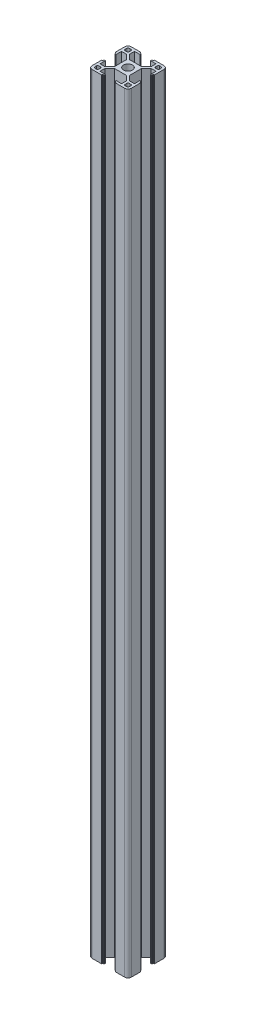
from build123d import *

# Parameters (mm, degrees)
SKETCH_3_R          = 3.4
EXTRUDE_1_DEPTH     = 589
SKETCH_4_R          = 3
CUT_EXTRUDE_1_DEPTH = 87


with BuildPart() as part:
    # 草图3 → 凸台-拉伸1 (new body)
    with BuildSketch(Plane(origin=(0, 0, 0), x_dir=(1, 0, 0), z_dir=(0, 1, 0))):
        with BuildLine():
            Line((-15, -12.5), (-15, -5.4))
            ThreePointArc((-15, -5.4), (-14.941421356, -5.258578644), (-14.8, -5.2))
            Line((-14.8, -5.2), (-14.4, -5.2))
            ThreePointArc((-14.4, -5.2), (-14.258578644, -5.141421356), (-14.2, -5))
            Line((-14.2, -5), (-14.2, -4.3))
            ThreePointArc((-14.2, -4.3), (-14.141421356, -4.158578644), (-14, -4.1))
            Line((-14, -4.1), (-13.2, -4.1))
            Line((-13.2, -4.1), (-13.2, -8.25))
            Line((-13.2, -8.25), (-9.522792206, -8.25))
            Line((-9.522792206, -8.25), (-5.8, -4.527207794))
            Line((-5.8, -4.527207794), (-5.8, 4.527207794))
            Line((-5.8, 4.527207794), (-9.522792206, 8.25))
            Line((-9.522792206, 8.25), (-13.2, 8.25))
            Line((-13.2, 8.25), (-13.2, 4.1))
            Line((-13.2, 4.1), (-14, 4.1))
            ThreePointArc((-14, 4.1), (-14.141421356, 4.158578644), (-14.2, 4.3))
            Line((-14.2, 4.3), (-14.2, 5))
            ThreePointArc((-14.2, 5), (-14.258578644, 5.141421356), (-14.4, 5.2))
            Line((-14.4, 5.2), (-14.8, 5.2))
            ThreePointArc((-14.8, 5.2), (-14.941421356, 5.258578644), (-15, 5.4))
            Line((-15, 5.4), (-15, 12.5))
            ThreePointArc((-15, 12.5), (-14.267766953, 14.267766953), (-12.5, 15))
            Line((-12.5, 15), (-5.4, 15))
            ThreePointArc((-5.4, 15), (-5.258578644, 14.941421356), (-5.2, 14.8))
            Line((-5.2, 14.8), (-5.2, 14.4))
            ThreePointArc((-5.2, 14.4), (-5.141421356, 14.258578644), (-5, 14.2))
            Line((-5, 14.2), (-4.3, 14.2))
            ThreePointArc((-4.3, 14.2), (-4.158578644, 14.141421356), (-4.1, 14))
            Line((-4.1, 14), (-4.1, 13.2))
            Line((-4.1, 13.2), (-8.25, 13.2))
            Line((-8.25, 13.2), (-8.25, 9.522792206))
            Line((-8.25, 9.522792206), (-4.527207794, 5.8))
            Line((-4.527207794, 5.8), (4.527207794, 5.8))
            Line((4.527207794, 5.8), (8.25, 9.522792206))
            Line((8.25, 9.522792206), (8.25, 13.2))
            Line((8.25, 13.2), (4.1, 13.2))
            Line((4.1, 13.2), (4.1, 14))
            ThreePointArc((4.1, 14), (4.158578644, 14.141421356), (4.3, 14.2))
            Line((4.3, 14.2), (5, 14.2))
            ThreePointArc((5, 14.2), (5.141421356, 14.258578644), (5.2, 14.4))
            Line((5.2, 14.4), (5.2, 14.8))
            ThreePointArc((5.2, 14.8), (5.258578644, 14.941421356), (5.4, 15))
            Line((5.4, 15), (12.5, 15))
            ThreePointArc((12.5, 15), (14.267766953, 14.267766953), (15, 12.5))
            Line((15, 12.5), (15, 5.4))
            ThreePointArc((15, 5.4), (14.941421356, 5.258578644), (14.8, 5.2))
            Line((14.8, 5.2), (14.4, 5.2))
            ThreePointArc((14.4, 5.2), (14.258578644, 5.141421356), (14.2, 5))
            Line((14.2, 5), (14.2, 4.3))
            ThreePointArc((14.2, 4.3), (14.141421356, 4.158578644), (14, 4.1))
            Line((14, 4.1), (13.2, 4.1))
            Line((13.2, 4.1), (13.2, 8.25))
            Line((13.2, 8.25), (9.522792206, 8.25))
            Line((9.522792206, 8.25), (5.8, 4.527207794))
            Line((5.8, 4.527207794), (5.8, -4.527207794))
            Line((5.8, -4.527207794), (9.522792206, -8.25))
            Line((9.522792206, -8.25), (13.2, -8.25))
            Line((13.2, -8.25), (13.2, -4.1))
            Line((13.2, -4.1), (14, -4.1))
            ThreePointArc((14, -4.1), (14.141421356, -4.158578644), (14.2, -4.3))
            Line((14.2, -4.3), (14.2, -5))
            ThreePointArc((14.2, -5), (14.258578644, -5.141421356), (14.4, -5.2))
            Line((14.4, -5.2), (14.8, -5.2))
            ThreePointArc((14.8, -5.2), (14.941421356, -5.258578644), (15, -5.4))
            Line((15, -5.4), (15, -12.5))
            ThreePointArc((15, -12.5), (14.267766953, -14.267766953), (12.5, -15))
            Line((12.5, -15), (5.4, -15))
            ThreePointArc((5.4, -15), (5.258578644, -14.941421356), (5.2, -14.8))
            Line((5.2, -14.8), (5.2, -14.4))
            ThreePointArc((5.2, -14.4), (5.141421356, -14.258578644), (5, -14.2))
            Line((5, -14.2), (4.3, -14.2))
            ThreePointArc((4.3, -14.2), (4.158578644, -14.141421356), (4.1, -14))
            Line((4.1, -14), (4.1, -13.2))
            Line((4.1, -13.2), (8.25, -13.2))
            Line((8.25, -13.2), (8.25, -9.522792206))
            Line((8.25, -9.522792206), (4.527207794, -5.8))
            Line((4.527207794, -5.8), (-4.527207794, -5.8))
            Line((-4.527207794, -5.8), (-8.25, -9.522792206))
            Line((-8.25, -9.522792206), (-8.25, -13.2))
            Line((-8.25, -13.2), (-4.1, -13.2))
            Line((-4.1, -13.2), (-4.1, -14))
            ThreePointArc((-4.1, -14), (-4.158578644, -14.141421356), (-4.3, -14.2))
            Line((-4.3, -14.2), (-5, -14.2))
            ThreePointArc((-5, -14.2), (-5.141421356, -14.258578644), (-5.2, -14.4))
            Line((-5.2, -14.4), (-5.2, -14.8))
            ThreePointArc((-5.2, -14.8), (-5.258578644, -14.941421356), (-5.4, -15))
            Line((-5.4, -15), (-12.5, -15))
            ThreePointArc((-12.5, -15), (-14.267766953, -14.267766953), (-15, -12.5))
        make_face()
        Circle(SKETCH_3_R, mode=Mode.SUBTRACT)
        with BuildLine():
            Line((-13.2, -12.2), (-13.2, -11.05))
            ThreePointArc((-13.2, -11.05), (-12.907106781, -10.342893219), (-12.2, -10.05))
            Line((-12.2, -10.05), (-11.05, -10.05))
            ThreePointArc((-11.05, -10.05), (-10.342893219, -10.342893219), (-10.05, -11.05))
            Line((-10.05, -11.05), (-10.05, -12.2))
            ThreePointArc((-10.05, -12.2), (-10.342893219, -12.907106781), (-11.05, -13.2))
            Line((-11.05, -13.2), (-12.2, -13.2))
            ThreePointArc((-12.2, -13.2), (-12.907106781, -12.907106781), (-13.2, -12.2))
        make_face(mode=Mode.SUBTRACT)
        with BuildLine():
            Line((-10.05, 12.2), (-10.05, 11.05))
            ThreePointArc((-10.05, 11.05), (-10.342893219, 10.342893219), (-11.05, 10.05))
            Line((-11.05, 10.05), (-12.2, 10.05))
            ThreePointArc((-12.2, 10.05), (-12.907106781, 10.342893219), (-13.2, 11.05))
            Line((-13.2, 11.05), (-13.2, 12.2))
            ThreePointArc((-13.2, 12.2), (-12.907106781, 12.907106781), (-12.2, 13.2))
            Line((-12.2, 13.2), (-11.05, 13.2))
            ThreePointArc((-11.05, 13.2), (-10.342893219, 12.907106781), (-10.05, 12.2))
        make_face(mode=Mode.SUBTRACT)
        with BuildLine():
            Line((13.2, 12.2), (13.2, 11.05))
            ThreePointArc((13.2, 11.05), (12.907106781, 10.342893219), (12.2, 10.05))
            Line((12.2, 10.05), (11.05, 10.05))
            ThreePointArc((11.05, 10.05), (10.342893219, 10.342893219), (10.05, 11.05))
            Line((10.05, 11.05), (10.05, 12.2))
            ThreePointArc((10.05, 12.2), (10.342893219, 12.907106781), (11.05, 13.2))
            Line((11.05, 13.2), (12.2, 13.2))
            ThreePointArc((12.2, 13.2), (12.907106781, 12.907106781), (13.2, 12.2))
        make_face(mode=Mode.SUBTRACT)
        with BuildLine():
            Line((10.05, -12.2), (10.05, -11.05))
            ThreePointArc((10.05, -11.05), (10.342893219, -10.342893219), (11.05, -10.05))
            Line((11.05, -10.05), (12.2, -10.05))
            ThreePointArc((12.2, -10.05), (12.907106781, -10.342893219), (13.2, -11.05))
            Line((13.2, -11.05), (13.2, -12.2))
            ThreePointArc((13.2, -12.2), (12.907106781, -12.907106781), (12.2, -13.2))
            Line((12.2, -13.2), (11.05, -13.2))
            ThreePointArc((11.05, -13.2), (10.342893219, -12.907106781), (10.05, -12.2))
        make_face(mode=Mode.SUBTRACT)
    extrude(amount=EXTRUDE_1_DEPTH)

    # 草图4 → 切除-拉伸1 (cut)
    with BuildSketch(Plane(origin=(0, 0, -5.8), x_dir=(-1, 0, 0), z_dir=(0, 0, -1))):
        with Locations((0, 439)):
            Circle(SKETCH_4_R)
        with Locations((0, 150)):
            Circle(SKETCH_4_R)
    extrude(amount=-CUT_EXTRUDE_1_DEPTH, mode=Mode.SUBTRACT)


solid = part.part
